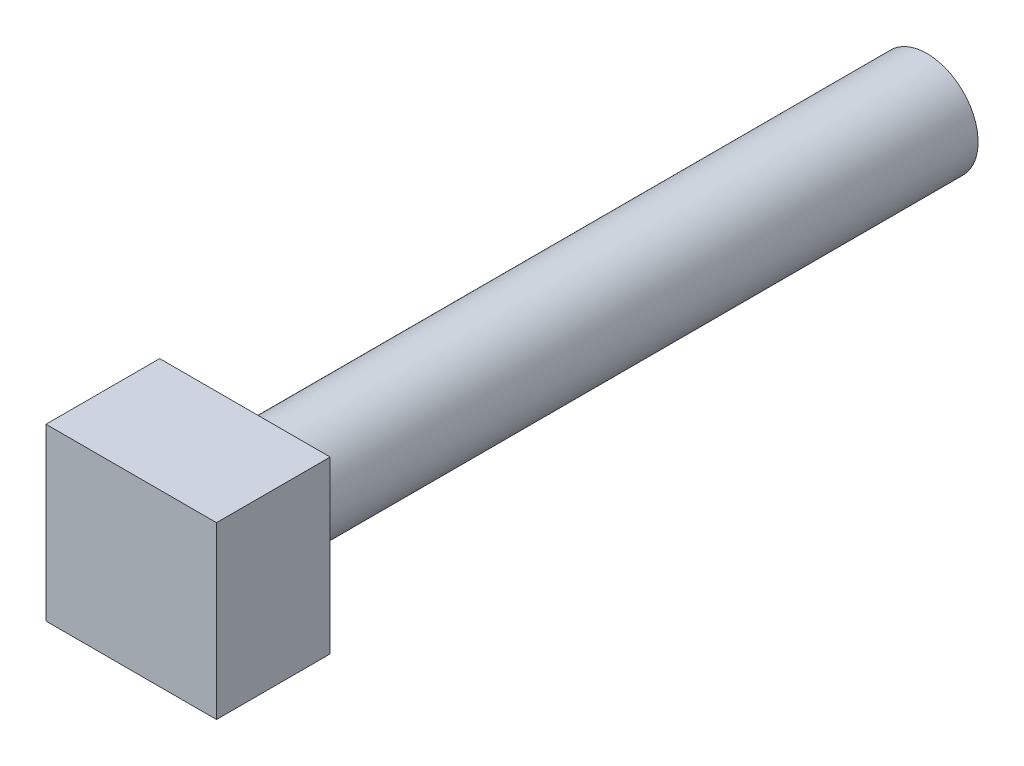
from build123d import *

# Parameters (mm, degrees)
SKETCH1_W           = 9.525
SKETCH1_H           = 9.525
BOSS_EXTRUDE1_DEPTH = 6.35
SKETCH2_R           = 2.8575
BOSS_EXTRUDE2_DEPTH = 38.1


with BuildPart() as part:
    # Sketch1 → Boss-Extrude1 (new body)
    with BuildSketch(Plane.XY):
        Rectangle(SKETCH1_W, SKETCH1_H)
    extrude(amount=BOSS_EXTRUDE1_DEPTH)

    # Sketch2 → Boss-Extrude2 (add)
    with BuildSketch(Plane(origin=(0, 0, 0), x_dir=(-1, 0, 0), z_dir=(0, 0, -1))):
        Circle(SKETCH2_R)
    extrude(amount=BOSS_EXTRUDE2_DEPTH)


solid = part.part
